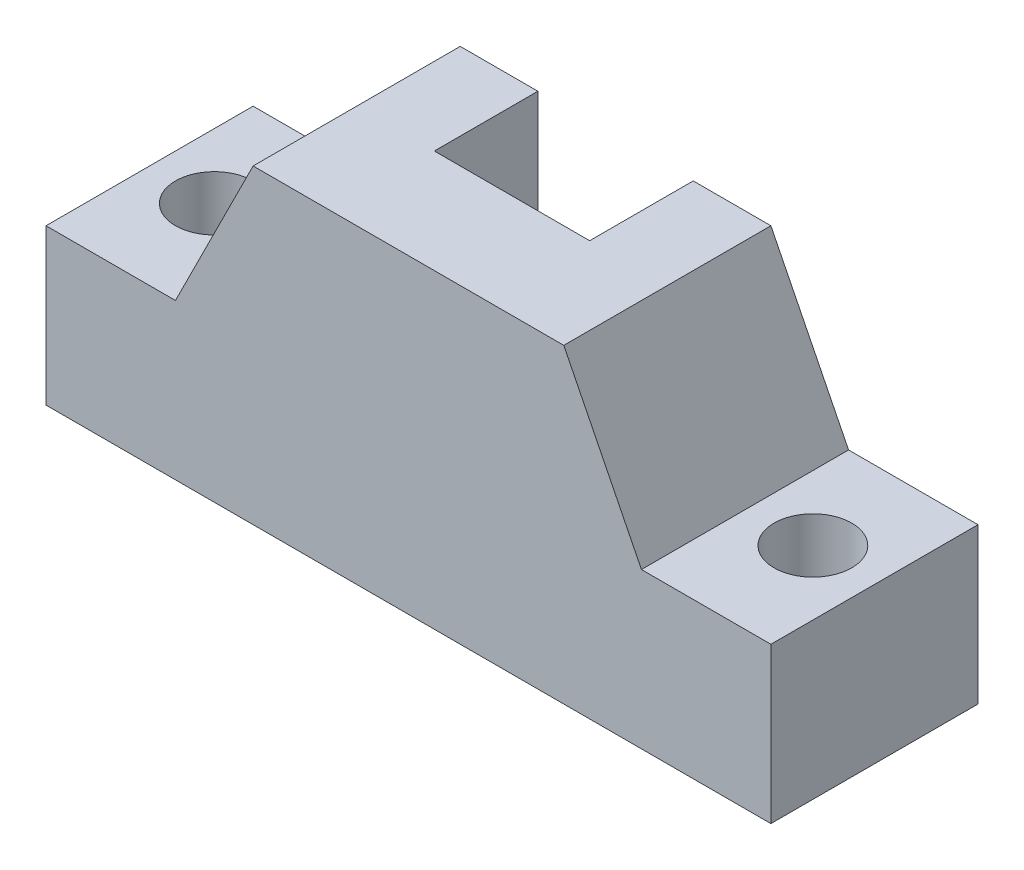
from build123d import *

# Parameters (mm, degrees)
SALIENTE_EXTRUIR1_DEPTH    = 40
CROQUIS2_R                 = 7.5
CORTAR_EXTRUIR1_DEPTH      = 40
CROQUIS3_R                 = 7.5
CORTAR_EXTRUIR2_DEPTH      = 40
CORTAR_EXTRUIR4_DEPTH      = 15
CORTAR_EXTRUIR4_DEPTH_BACK = 15


with BuildPart() as part:
    # Croquis1 → Saliente-Extruir1 (new body)
    with BuildSketch(Plane.XY):
        Polygon((0, 0), (140, 0), (140, 30), (115, 30), (100, 60), (40, 60), (25, 30), (0, 30), align=None)
    extrude(amount=SALIENTE_EXTRUIR1_DEPTH)

    # Croquis2 → Cortar-Extruir1 (cut)
    with BuildSketch(Plane(origin=(0, 30, 0), x_dir=(1, 0, 0), z_dir=(0, 1, 0))):
        with Locations((127.532427411, -19.421880323)):
            Circle(CROQUIS2_R)
    extrude(amount=-CORTAR_EXTRUIR1_DEPTH, mode=Mode.SUBTRACT)

    # Croquis3 → Cortar-Extruir2 (cut)
    with BuildSketch(Plane(origin=(0, 30, 0), x_dir=(1, 0, 0), z_dir=(0, 1, 0))):
        with Locations((12.5, -20)):
            Circle(CROQUIS3_R)
    extrude(amount=-CORTAR_EXTRUIR2_DEPTH, mode=Mode.SUBTRACT)

    # Croquis16 → Cortar-Extruir4 (cut, two sides)
    with BuildSketch(Plane(origin=(70, 0, 0), x_dir=(0, 0, -1), z_dir=(1, 0, 0))) as cortar_extruir4_sk:
        Polygon((0, 60), (-20, 60), (0, 25.358983849), align=None)
    extrude(amount=CORTAR_EXTRUIR4_DEPTH, mode=Mode.SUBTRACT)
    extrude(cortar_extruir4_sk.sketch, amount=-CORTAR_EXTRUIR4_DEPTH_BACK, mode=Mode.SUBTRACT)


solid = part.part
